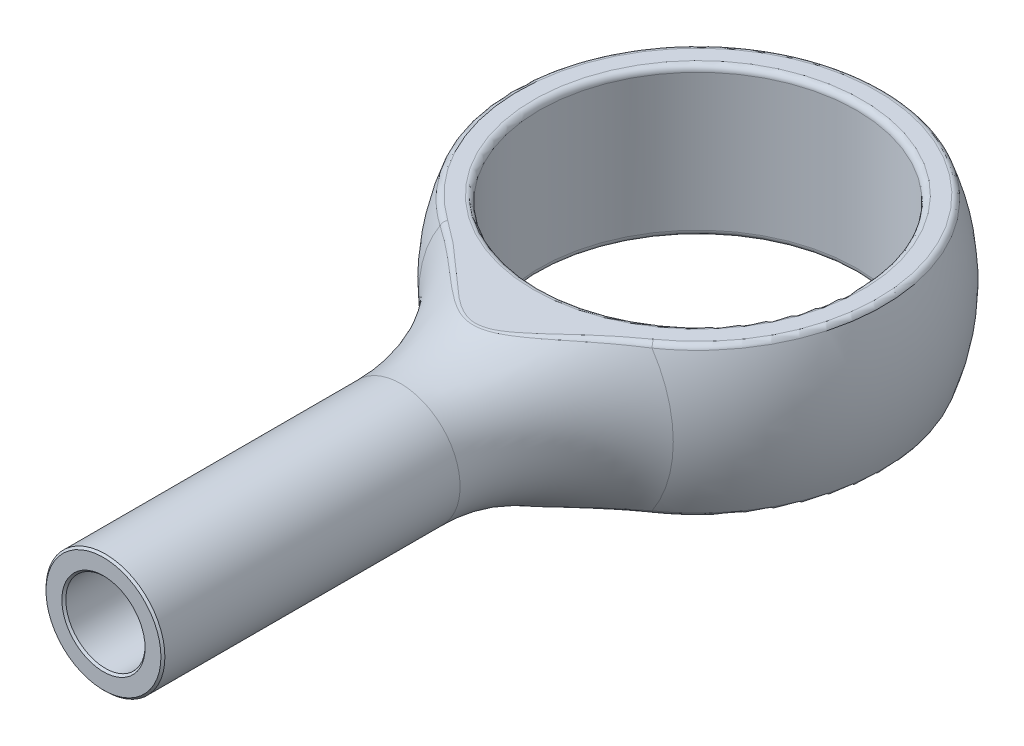
from build123d import *

# Parameters (mm, degrees)
CUT_EXTRUDE1_DEPTH      = 10
CUT_EXTRUDE1_DEPTH_BACK = 10
SKETCH5_R               = 4
CUT_EXTRUDE2_DEPTH      = 10
CUT_EXTRUDE2_DEPTH_BACK = 10
FILLET1_R               = 0.15
FILLET2_R               = 0.15
SKETCH6_R               = 1
CUT_EXTRUDE3_DEPTH      = 5
CHAMFER1_SIZE           = 0.05


with BuildPart() as part:
    # Sketch2 → Revolve1 (revolve)
    with BuildSketch(Plane(origin=(0, 0, 0), x_dir=(1, 0, 0), z_dir=(0, 1, 0))):
        with BuildLine():
            Line((-1.5, -15), (0, -15))
            Line((0, -15), (0, 5))
            ThreePointArc((0, 5), (-4.698967117, 1.708715315), (-3.211678832, -3.832116788))
            ThreePointArc((-3.211678832, -3.832116788), (-1.948980687, -5.476190987), (-1.5, -7.5))
            Line((-1.5, -7.5), (-1.5, -15))
        make_face()
    revolve(axis=Axis((0, 0, -5), (0, 0, 1)))

    # Sketch4 → Cut-Extrude1 (cut, two sides)
    with BuildSketch(Plane(origin=(0, 0, 0), x_dir=(0, 0, -1), z_dir=(1, 0, 0))) as cut_extrude1_sk:
        with BuildLine():
            Line((-21.365147595, 11.777353688), (10.763184779, 11.777353688))
            Line((10.763184779, 11.777353688), (10.763184779, 1.875))
            Line((10.763184779, 1.875), (-5.64662697, 1.875))
            ThreePointArc((-5.64662697, 1.875), (-7.150155967, 2.106415246), (-8.514509151, 2.779239779))
            Line((-8.514509151, 2.779239779), (-21.365147595, 11.777353688))
        make_face()
        with BuildLine():
            Line((-8.514509151, -2.779239779), (-21.365147595, -11.777353688))
            Line((-21.365147595, -11.777353688), (10.763184779, -11.777353688))
            Line((10.763184779, -11.777353688), (10.763184779, -1.875))
            Line((10.763184779, -1.875), (-5.64662697, -1.875))
            ThreePointArc((-5.64662697, -1.875), (-7.150155967, -2.106415246), (-8.514509151, -2.779239779))
        make_face()
    extrude(amount=CUT_EXTRUDE1_DEPTH, mode=Mode.SUBTRACT)
    extrude(cut_extrude1_sk.sketch, amount=-CUT_EXTRUDE1_DEPTH_BACK, mode=Mode.SUBTRACT)

    # Sketch5 → Cut-Extrude2 (cut, two sides)
    with BuildSketch(Plane(origin=(0, 0, 0), x_dir=(1, 0, 0), z_dir=(0, 1, 0))) as cut_extrude2_sk:
        Circle(SKETCH5_R)
    extrude(amount=CUT_EXTRUDE2_DEPTH, mode=Mode.SUBTRACT)
    extrude(cut_extrude2_sk.sketch, amount=-CUT_EXTRUDE2_DEPTH_BACK, mode=Mode.SUBTRACT)

    # Fillet1
    fillet1_edges = [part.edges().sort_by_distance(p)[0] for p in [
        (1e-09, -1.875, 5.642942998),
        (-1e-09, 1.875, 5.642942998),
        (0, 1.875, -4.635124054),
        (0, -1.875, -4.635124054),
        (-4, 1.875, 0),
    ]]
    fillet(fillet1_edges, radius=FILLET1_R)

    # Fillet2
    fillet2_edges = [part.edges().sort_by_distance(p)[0] for p in [
        (-4, -1.875, 0),
    ]]
    fillet(fillet2_edges, radius=FILLET2_R)

    # Sketch6 → Cut-Extrude3 (cut)
    with BuildSketch(Plane.XY.offset(15)):
        Circle(SKETCH6_R)
    extrude(amount=-CUT_EXTRUDE3_DEPTH, mode=Mode.SUBTRACT)

    # Chamfer1
    chamfer1_edges = [part.edges().sort_by_distance(p)[0] for p in [
        (1.5, 0, 15),
        (-1, 0, 15),
    ]]
    chamfer(chamfer1_edges, length=CHAMFER1_SIZE)


solid = part.part
